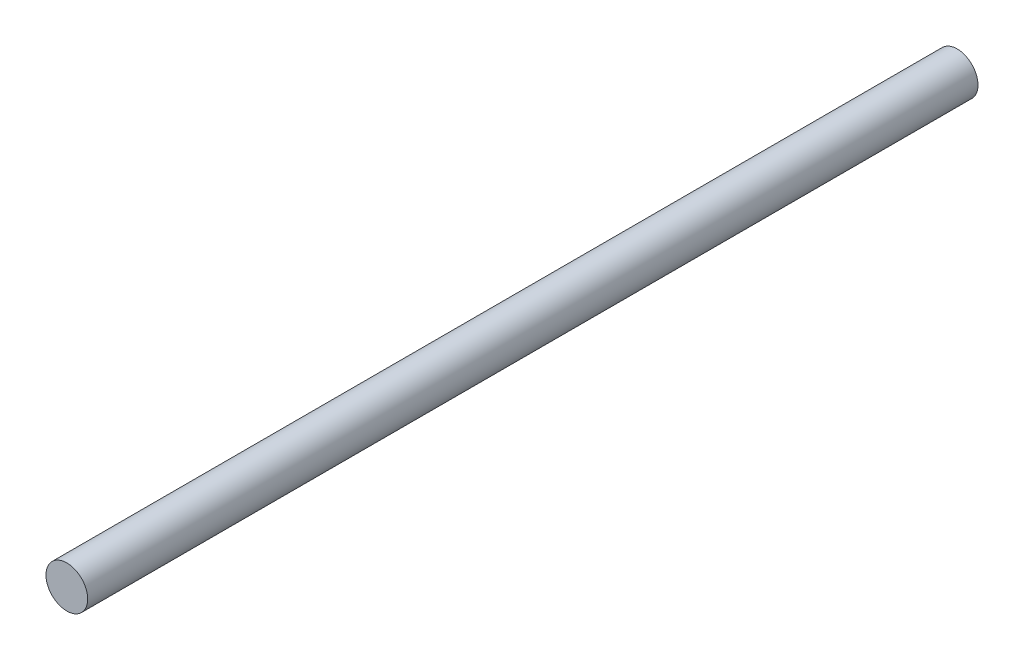
from build123d import *

# Parameters (mm, degrees)
SKETCH1_R           = 2.38125
BOSS_EXTRUDE1_DEPTH = 101.6


with BuildPart() as part:
    # Sketch1 → Boss-Extrude1 (new body)
    with BuildSketch(Plane.XY):
        Circle(SKETCH1_R)
    extrude(amount=BOSS_EXTRUDE1_DEPTH)


solid = part.part
